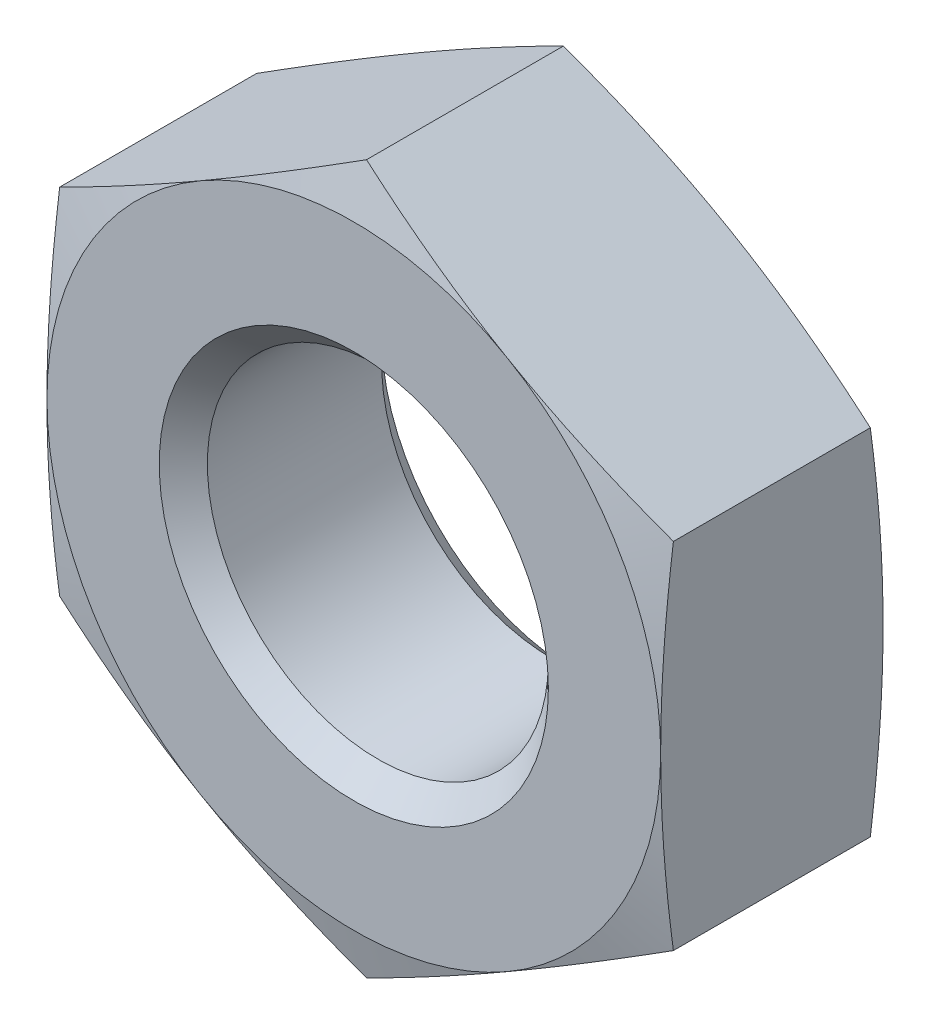
from build123d import *

# Parameters (mm, degrees)
SKETCH2_W          = 35.052
SKETCH2_H          = 35.052
CUT_EXTRUDE1_DEPTH = 6.35


with BuildPart() as part:
    # Sketch1 → Revolve1 (revolve)
    with BuildSketch(Plane(origin=(0, 0, 0), x_dir=(0, 0, -1), z_dir=(1, 0, 0))):
        Polygon((0, 0), (0, 8.763), (0.469607755, 10.5156), (5.880392245, 10.5156), (6.35, 8.763), (6.35, 0), align=None)
    revolve(axis=Axis((0, 0, -6.35), (0, 0, 1)))

    # Sketch2 → Cut-Extrude1 (cut)
    with BuildSketch(Plane.XY):
        Rectangle(SKETCH2_W, SKETCH2_H)
        Polygon((-8.763, 5.059320409), (-8.763, -5.059320409), (0, -10.118640818), (8.763, -5.059320409), (8.763, 5.059320409), (0, 10.118640818), align=None, mode=Mode.SUBTRACT)
    extrude(amount=-CUT_EXTRUDE1_DEPTH, mode=Mode.SUBTRACT)

    # Sketch3 → Cut-Revolve1 (revolve, cut)
    with BuildSketch(Plane(origin=(0, 0, 0), x_dir=(0, 0, -1), z_dir=(1, 0, 0))):
        Polygon((0, 0), (0, 5.55625), (0.68707, 4.86918), (5.66293, 4.86918), (6.35, 5.55625), (6.35, 0), align=None)
    revolve(axis=Axis((0, 0, -6.35), (0, 0, 1)), mode=Mode.SUBTRACT)


solid = part.part
